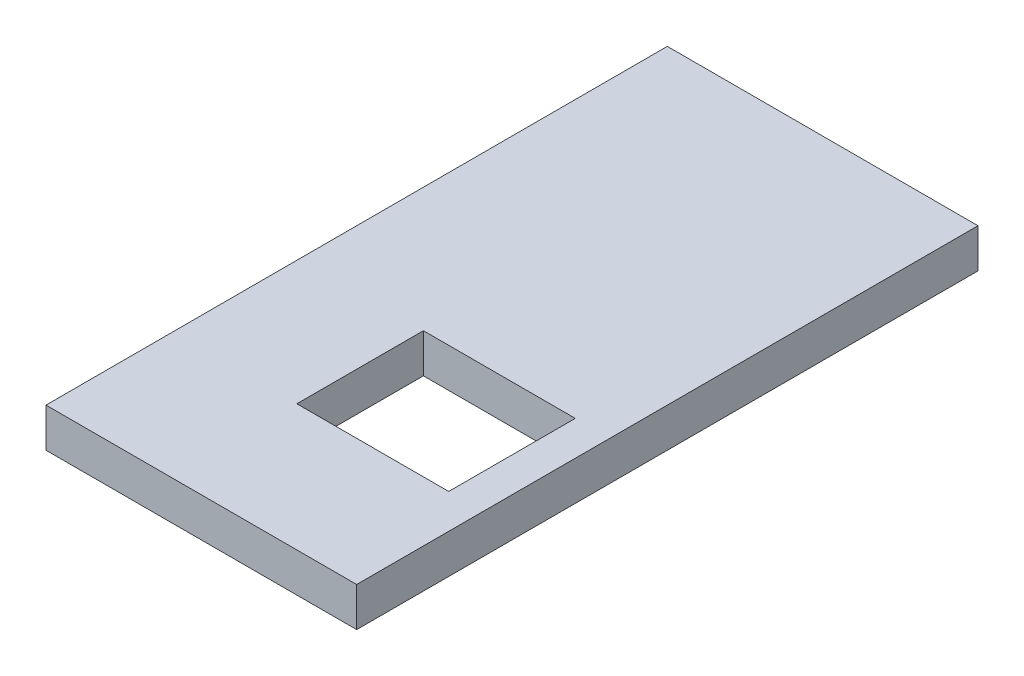
from build123d import *

# Parameters (mm, degrees)
ESBO_O1_W                = 1350
ESBO_O1_H                = 170
RESSALTO_EXTRUS_O1_DEPTH = 2700
ESBO_O2_W                = 660
ESBO_O2_H                = 550
CORTE_EXTRUS_O1_DEPTH    = 171


with BuildPart() as part:
    # Esboço1 → Ressalto-extrusão1 (new body)
    with BuildSketch(Plane.XY):
        with Locations((675, 85)):
            Rectangle(ESBO_O1_W, ESBO_O1_H)
    extrude(amount=RESSALTO_EXTRUS_O1_DEPTH)

    # Esboço2 → Corte-extrusão1 (cut, through all)
    with BuildSketch(Plane(origin=(0, 170, 0), x_dir=(1, 0, 0), z_dir=(0, 1, 0))):
        with Locations((870, -1875)):
            Rectangle(ESBO_O2_W, ESBO_O2_H)
    extrude(amount=-CORTE_EXTRUS_O1_DEPTH, mode=Mode.SUBTRACT)


solid = part.part
